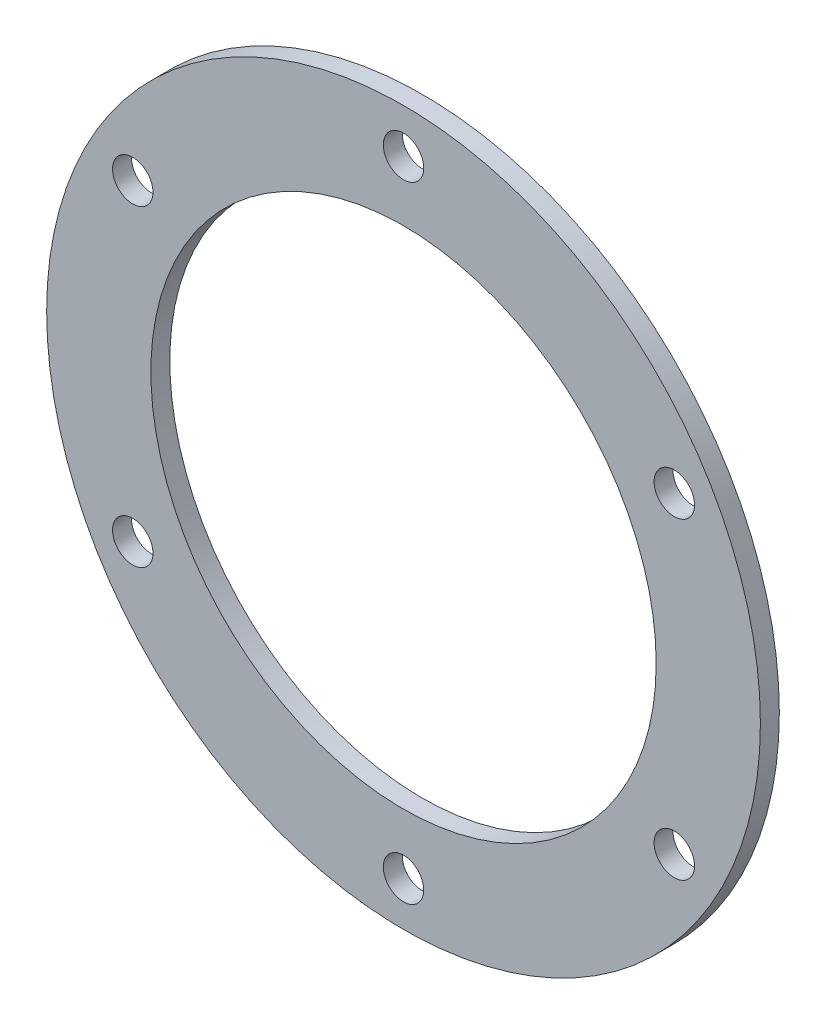
from build123d import *

# Parameters (mm, degrees)
SKETCH_1_R          = 28.25
SKETCH_1_R_2        = 20
EXTRUDE_1_DEPTH     = 1.5
SKETCH_2_R          = 1.6
CUT_EXTRUDE_1_DEPTH = 1.5


with BuildPart() as part:
    # 草图1 → 凸台-拉伸1 (new body)
    with BuildSketch(Plane.XY):
        Circle(SKETCH_1_R)
        Circle(SKETCH_1_R_2, mode=Mode.SUBTRACT)
    extrude(amount=EXTRUDE_1_DEPTH)

    # 草图2 → 切除-拉伸1 (cut)
    with BuildSketch(Plane.XY.offset(1.5)):
        with Locations((0, 24.75)):
            Circle(SKETCH_2_R)
        with Locations((21.434128744, 12.375)):
            Circle(SKETCH_2_R)
        with Locations((21.434128744, -12.375)):
            Circle(SKETCH_2_R)
        with Locations((0, -24.75)):
            Circle(SKETCH_2_R)
        with Locations((-21.434128744, -12.375)):
            Circle(SKETCH_2_R)
        with Locations((-21.434128744, 12.375)):
            Circle(SKETCH_2_R)
    extrude(amount=-CUT_EXTRUDE_1_DEPTH, mode=Mode.SUBTRACT)


solid = part.part
